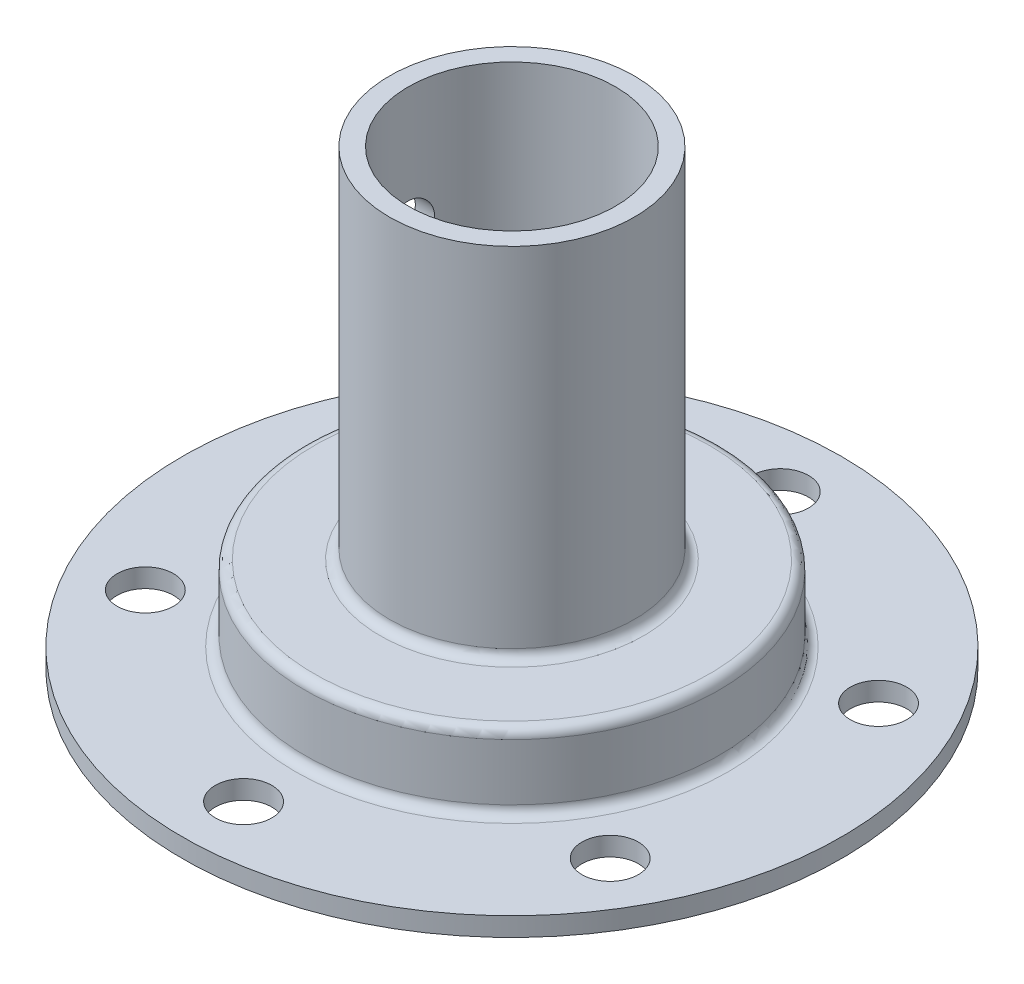
from build123d import *

# Parameters (mm, degrees)
SKETCH_2_R          = 3
CUT_EXTRUDE_1_DEPTH = 3
SKETCH_3_R          = 2.5
CUT_EXTRUDE_2_DEPTH = 36


with BuildPart() as part:
    # 草图1 → 旋转1 (revolve)
    with BuildSketch(Plane.XY):
        with BuildLine():
            Line((20, 0), (35, 0))
            Line((35, 0), (35, 2))
            Line((35, 2), (23, 2))
            ThreePointArc((23, 2), (22.292893219, 2.292893219), (22, 3))
            Line((22, 3), (22, 9))
            ThreePointArc((22, 9), (21.707106781, 9.707106781), (21, 10))
            Line((21, 10), (14, 10))
            ThreePointArc((14, 10), (13.292893219, 10.292893219), (13, 11))
            Line((13, 11), (13, 48))
            Line((13, 48), (11, 48))
            Line((11, 48), (11, 8))
            Line((11, 8), (19, 8))
            ThreePointArc((19, 8), (19.707106781, 7.707106781), (20, 7))
            Line((20, 7), (20, 0))
        make_face()
    revolve(axis=Axis((0, 0, 0), (0, 1, 0)))

    # 草图2 → 切除-拉伸1 (cut, through all)
    with BuildSketch(Plane(origin=(0, 2, 0), x_dir=(1, 0, 0), z_dir=(0, 1, 0))):
        with Locations((0, 28.5)):
            Circle(SKETCH_2_R)
        with Locations((24.681724008, 14.25)):
            Circle(SKETCH_2_R)
        with Locations((24.681724008, -14.25)):
            Circle(SKETCH_2_R)
        with Locations((0, -28.5)):
            Circle(SKETCH_2_R)
        with Locations((-24.681724008, -14.25)):
            Circle(SKETCH_2_R)
        with Locations((-24.681724008, 14.25)):
            Circle(SKETCH_2_R)
    extrude(amount=-CUT_EXTRUDE_1_DEPTH, mode=Mode.SUBTRACT)

    # 草图3 → 切除-拉伸2 (cut, through all)
    with BuildSketch(Plane(origin=(0, 0, 0), x_dir=(0, 0, -1), z_dir=(1, 0, 0))):
        with Locations((0, 35)):
            Circle(SKETCH_3_R)
    extrude(amount=-CUT_EXTRUDE_2_DEPTH, mode=Mode.SUBTRACT)


solid = part.part
